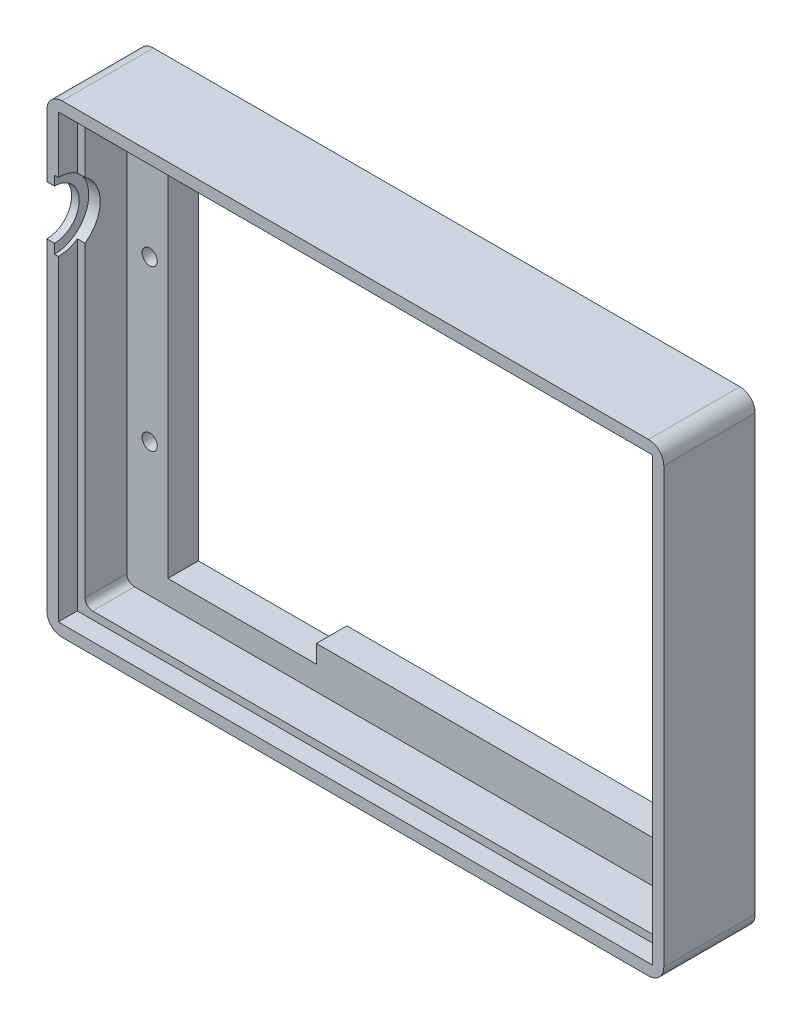
from build123d import *

# Parameters (mm, degrees)
ESQUISSE1_W                     = 81
ESQUISSE1_H                     = 61
ESQUISSE1_W_2                   = 65
ESQUISSE1_H_2                   = 45
EXTRU_MINCE1_DEPTH              = 4
ESQUISSE3_R                     = 1
ENL_V_MAT_EXTRU_1_DEPTH         = 13
ESQUISSE4_W                     = 81
ESQUISSE4_H                     = 61
ESQUISSE4_W_2                   = 76
ESQUISSE4_H_2                   = 56
EXTRU_MINCE2_DEPTH              = 12
ENL_V_MAT_EXTRU_5_DEPTH         = 11.5
ENL_V_MAT_EXTRU_4_DEPTH         = 1.5
ESQUISSE9_W                     = 78
ESQUISSE9_H                     = 58
ESQUISSE9_W_2                   = 76
ESQUISSE9_H_2                   = 56
ENL_V_DE_MAT_EXTRU_MINCE1_DEPTH = 2.5
CONG_4_R                        = 1
CONG_5_R                        = 2


with BuildPart() as part:
    # Esquisse1 → Extru.-Mince1 (new body)
    with BuildSketch(Plane.XY):
        with Locations((32.5, 22.5)):
            Rectangle(ESQUISSE1_W, ESQUISSE1_H)
        with Locations((32.5, 22.5)):
            Rectangle(ESQUISSE1_W_2, ESQUISSE1_H_2, mode=Mode.SUBTRACT)
    extrude(amount=EXTRU_MINCE1_DEPTH)

    # Esquisse3 → Enlèv. mat.-Extru.1 (cut)
    with BuildSketch(Plane.XY):
        with Locations((-2.5, 33)):
            Circle(ESQUISSE3_R)
        with Locations((-2.5, 12)):
            Circle(ESQUISSE3_R)
        with Locations((67.5, 33)):
            Circle(ESQUISSE3_R)
        with Locations((67.5, 12)):
            Circle(ESQUISSE3_R)
        Polygon((-0.11, 47.36), (19.39, 47.36), (19.39, 43.36), (19.39, 1.64), (19.39, -2.36), (-0.11, -2.36), (-0.11, 1.64), (-0.11, 43.36), align=None)
    extrude(amount=ENL_V_MAT_EXTRU_1_DEPTH, mode=Mode.SUBTRACT)

    # Esquisse4 → Extru.-Mince2 (add)
    with BuildSketch(Plane.XY):
        with Locations((32.5, 22.5)):
            Rectangle(ESQUISSE4_W, ESQUISSE4_H)
        with Locations((32.5, 22.5)):
            Rectangle(ESQUISSE4_W_2, ESQUISSE4_H_2, mode=Mode.SUBTRACT)
    extrude(amount=EXTRU_MINCE2_DEPTH)

    # Esquisse7 → Enlèv. mat.-Extru.5 (cut)
    with BuildSketch(Plane(origin=(-5.5, 0, 0), x_dir=(0, 0, -1), z_dir=(1, 0, 0))):
        with BuildLine():
            Line((-12, 42.802969616), (-12, 36.302969616))
            ThreePointArc((-12, 36.302969616), (-8.75, 39.552969616), (-12, 42.802969616))
        make_face()
    extrude(amount=-ENL_V_MAT_EXTRU_5_DEPTH, mode=Mode.SUBTRACT)

    # Esquisse6 → Enlèv. mat.-Extru.4 (cut)
    with BuildSketch(Plane(origin=(-5.5, 0, 0), x_dir=(0, 0, -1), z_dir=(1, 0, 0))):
        with BuildLine():
            Line((-12, 44.052969616), (-12, 35.052969616))
            ThreePointArc((-12, 35.052969616), (-7.5, 39.552969616), (-12, 44.052969616))
        make_face()
    extrude(amount=-ENL_V_MAT_EXTRU_4_DEPTH, mode=Mode.SUBTRACT)

    # Esquisse9 → Enlèv. de mat.-Extru.-Mince1 (cut)
    with BuildSketch(Plane.XY.offset(12)):
        with Locations((32.5, 22.5)):
            Rectangle(ESQUISSE9_W, ESQUISSE9_H)
        with Locations((32.5, 22.5)):
            Rectangle(ESQUISSE9_W_2, ESQUISSE9_H_2, mode=Mode.SUBTRACT)
    extrude(amount=-ENL_V_DE_MAT_EXTRU_MINCE1_DEPTH, mode=Mode.SUBTRACT)

    # Congé4
    cong_4_edges = [part.edges().sort_by_distance(p)[0] for p in [
        (-5.5, 50.5, 6.75),
        (70.5, 50.5, 6.75),
        (70.5, -5.5, 6.75),
        (-5.5, -5.5, 6.75),
    ]]
    fillet(cong_4_edges, radius=CONG_4_R)

    # Congé5
    cong_5_edges = [part.edges().sort_by_distance(p)[0] for p in [
        (-8, 53, 6),
        (73, 53, 6),
        (73, -8, 6),
        (-8, -8, 6),
    ]]
    fillet(cong_5_edges, radius=CONG_5_R)


solid = part.part
